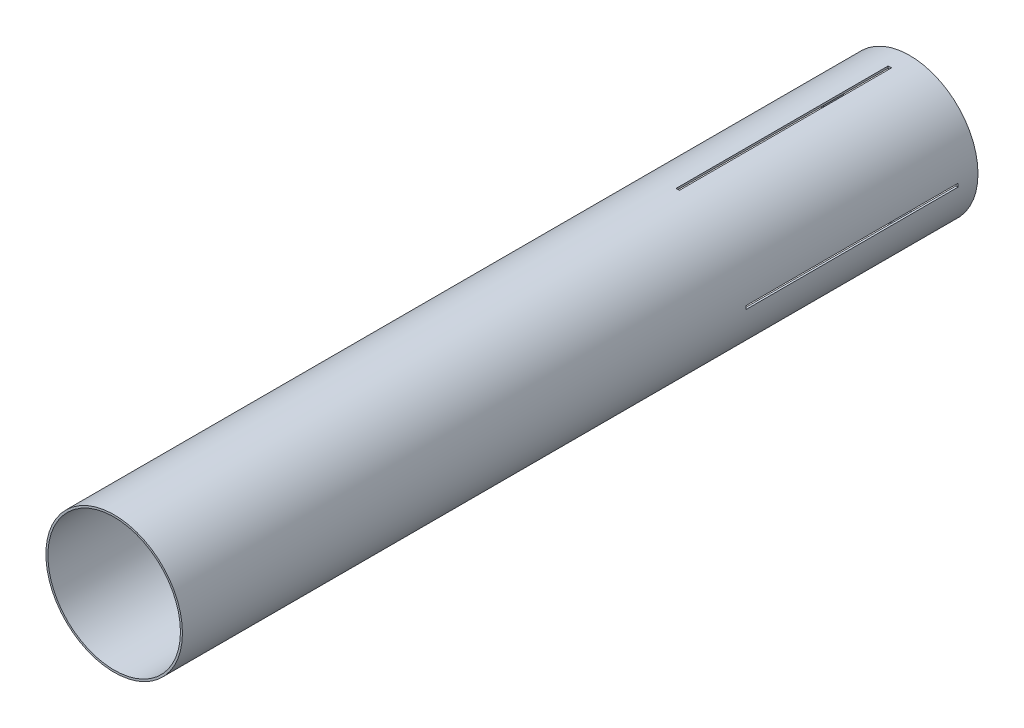
from build123d import *

# Parameters (mm, degrees)
SKETCH1_R           = 65.405
SKETCH1_R_2         = 63.5
BOSS_EXTRUDE1_DEPTH = 381
SKETCH3_W           = 3.175
SKETCH3_H           = 203.2
CUT_EXTRUDE1_DEPTH  = 66.405
CIRPATTERN1_COUNT   = 4


with BuildPart() as part:
    # Sketch1 → Boss-Extrude1 (new body, symmetric)
    with BuildSketch(Plane.XY):
        Circle(SKETCH1_R)
        Circle(SKETCH1_R_2, mode=Mode.SUBTRACT)
    extrude(amount=BOSS_EXTRUDE1_DEPTH, both=True)

    # Sketch3 → Cut-Extrude1 (cut, through all)
    with BuildSketch(Plane(origin=(0, 0, 0), x_dir=(1, 0, 0), z_dir=(0, 1, 0))):
        with Locations((0, 260.35)):
            Rectangle(SKETCH3_W, SKETCH3_H)
    cut_extrude1 = extrude(amount=CUT_EXTRUDE1_DEPTH, mode=Mode.SUBTRACT)

    # CirPattern1: Cut-Extrude1 ×4 about axis
    cirpattern1_axis = Axis((0, 0, 0), (0, 0, 1))
    for i in range(1, CIRPATTERN1_COUNT):
        add(cut_extrude1.rotate(cirpattern1_axis, i * 360 / CIRPATTERN1_COUNT), mode=Mode.SUBTRACT)


solid = part.part
